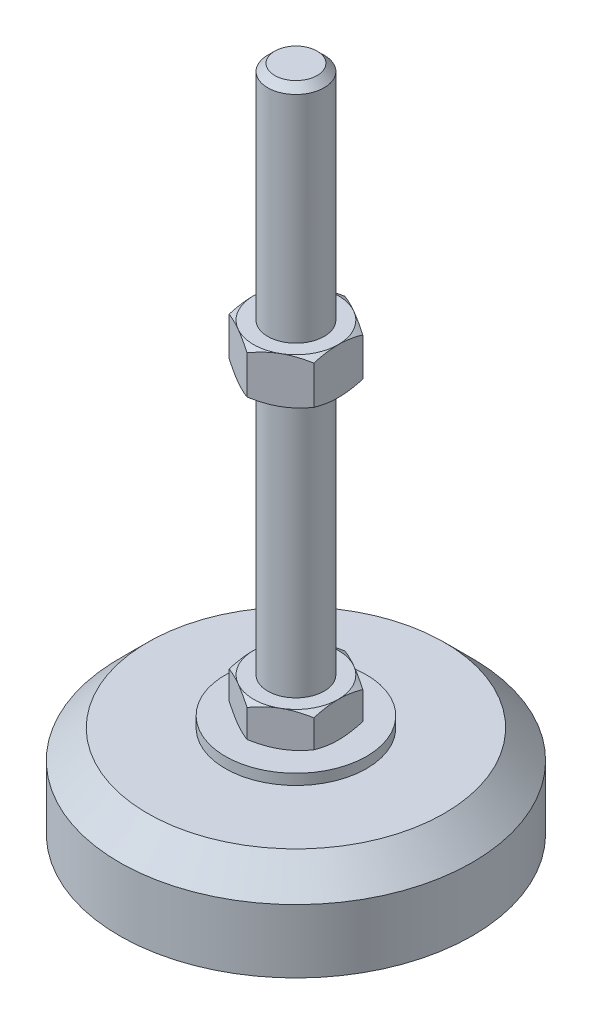
from build123d import *

# Parameters (mm, degrees)
EXTRUDE_1_DEPTH = 10
EXTRUDE_2_DEPTH = 13


with BuildPart() as part:
    # Эскиз1 → Повернуть1 (revolve)
    with BuildSketch(Plane.XY, mode=Mode.PRIVATE) as revolve_1_sk:
        Polygon((0, 0), (-50, 0), (-50, 18), (-42, 26), (-20, 26), (-20, 29), (-8, 29), (-8, 39), (-8, 187), (-6, 189), (0, 189), align=None)
    revolve(revolve_1_sk.sketch.rotate(Axis((0, 0, 0), (0, 1, 0)), 180), axis=Axis((0, 0, 0), (0, 1, 0)))  # turned: the seam where the file's is

    # Эскиз2 → Бобышка-Вытянуть1 (add)
    with BuildSketch(Plane(origin=(0, 29, 0), x_dir=(1, 0, 0), z_dir=(0, 1, 0))):
        Polygon((0, 13.856406461), (-12, 6.92820323), (-12, -6.92820323), (0, -13.856406461), (12, -6.92820323), (12, 6.92820323), align=None)
    extrude(amount=EXTRUDE_1_DEPTH)

    # Эскиз3 → Бобышка-Вытянуть2 (add)
    with BuildSketch(Plane(origin=(0, 113, 0), x_dir=(1, 0, 0), z_dir=(0, 1, 0))):
        Polygon((12, 6.92820323), (0, 13.856406461), (-12, 6.92820323), (-12, -6.92820323), (0, -13.856406461), (12, -6.92820323), align=None)
    extrude(amount=EXTRUDE_2_DEPTH)

    # Эскиз4 → Вырез-Повернуть2 (revolve, cut)
    with BuildSketch(Plane.XY, mode=Mode.PRIVATE) as cut_revolve_2_sk:
        Polygon((-23.258330249, 126), (-12, 126), (-23.258330249, 119.5), align=None)
        Polygon((-23.258330249, 113), (-23.258330249, 119.5), (-12, 113), align=None)
        Polygon((-20.660254038, 39), (-20.660254038, 34), (-12, 39), align=None)
        Polygon((-20.660254038, 34), (-20.660254038, 29), (-12, 29), align=None)
    revolve(cut_revolve_2_sk.sketch.rotate(Axis((0, 189, 0), (0, -1, 0)), 180), axis=Axis((0, 189, 0), (0, -1, 0)), mode=Mode.SUBTRACT)  # turned: the seam where the file's is


solid = part.part
